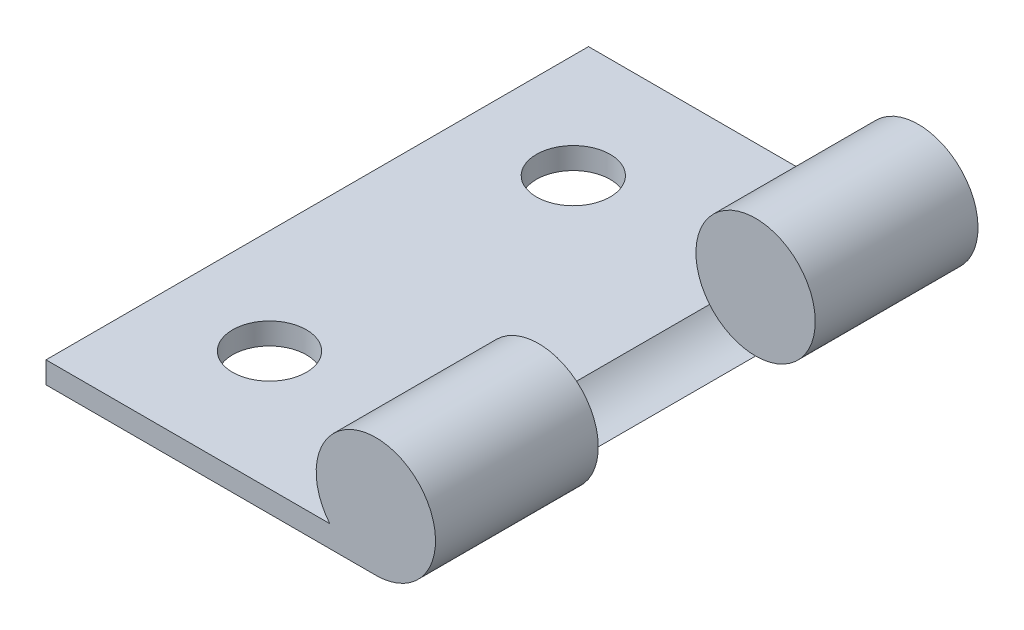
from build123d import *

# Parameters (mm, degrees)
EXTRUDE_1_DEPTH     = 25
SKETCH_2_R          = 1.7
CUT_EXTRUDE_1_DEPTH = 25
CUT_EXTRUDE_START   = -7.5
SKETCH_3_R          = 2.75
CUT_EXTRUDE_2_DEPTH = 10


with BuildPart() as part:
    # 草图1 → 凸台-拉伸1 (new body)
    with BuildSketch(Plane.XY):
        with BuildLine():
            Line((0, -2.75), (-15.2, -2.75))
            Line((-15.2, -2.75), (-15.2, -1.75))
            Line((-15.2, -1.75), (-2.121320344, -1.75))
            ThreePointArc((-2.121320344, -1.75), (1.17260394, 2.487468593), (0, -2.75))
        make_face()
    extrude(amount=EXTRUDE_1_DEPTH)

    # 草图2 → 切除-拉伸1 (cut)
    with BuildSketch(Plane(origin=(0, -1.75, 0), x_dir=(1, 0, 0), z_dir=(0, 1, 0))):
        with Locations((-10.4, -5.5)):
            Circle(SKETCH_2_R)
        with Locations((-10.4, -19.5)):
            Circle(SKETCH_2_R)
    extrude(amount=-CUT_EXTRUDE_1_DEPTH, mode=Mode.SUBTRACT)

    # 草图3 → 切除-拉伸2 (cut)
    with BuildSketch(Plane(origin=(0, 0, 0), x_dir=(-1, 0, 0), z_dir=(0, 0, -1)).offset(CUT_EXTRUDE_START)):
        Circle(SKETCH_3_R)
    extrude(amount=-CUT_EXTRUDE_2_DEPTH, mode=Mode.SUBTRACT)


solid = part.part
